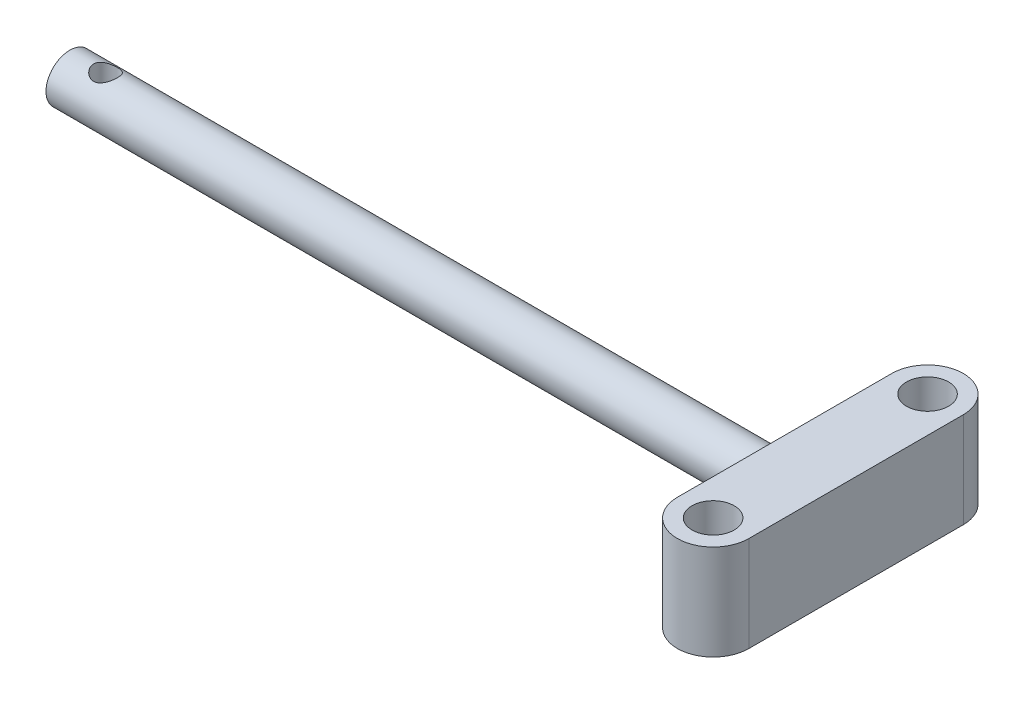
from build123d import *

# Parameters (mm, degrees)
BOSS_EXTRUDE1_DEPTH = 5.08
CUT_EXTRUDE1_REACH  = 12.16
SKETCH4_R           = 2.2479
SKETCH5_R           = 2.54
BOSS_EXTRUDE2_DEPTH = 76.2
CUT_EXTRUDE5_REACH  = 9.62
SKETCH6_R           = 1.27


with BuildPart() as part:
    # Sketch2 → Boss-Extrude1 (new body, symmetric)
    with BuildSketch(Plane(origin=(0, 0, 0), x_dir=(1, 0, 0), z_dir=(0, 1, 0))):
        with BuildLine():
            Line((-50.935337995, 2.421627074), (-50.935337995, -2.138056527))
            Line((-50.935337995, -2.138056527), (-50.935337995, -11.43))
            ThreePointArc((-50.935337995, -11.43), (-47.125337995, -15.24), (-43.315337995, -11.43))
            Line((-43.315337995, -11.43), (-43.315337995, 11.43))
            ThreePointArc((-43.315337995, 11.43), (-47.125337995, 15.24), (-50.935337995, 11.43))
            Line((-50.935337995, 11.43), (-50.935337995, 2.421627074))
        make_face()
    extrude(amount=BOSS_EXTRUDE1_DEPTH, both=True)

    # Sketch4 → Cut-Extrude1 (cut, up to next)
    with BuildSketch(Plane(origin=(0, 5.08, 0), x_dir=(1, 0, 0), z_dir=(0, 1, 0)), mode=Mode.PRIVATE) as cut_extrude1_sk1:
        with Locations((-47.125337995, 11.43)):
            Circle(SKETCH4_R)
    cut_extrude1_tool1 = extrude(cut_extrude1_sk1.sketch, amount=-CUT_EXTRUDE1_REACH, mode=Mode.PRIVATE) & part.part
    add(cut_extrude1_tool1.solids().sort_by_distance((-47.125338, 5.08, -11.43))[0], mode=Mode.SUBTRACT)
    # Sketch4 → Cut-Extrude1 (cut, up to next)
    with BuildSketch(Plane(origin=(0, 5.08, 0), x_dir=(1, 0, 0), z_dir=(0, 1, 0)), mode=Mode.PRIVATE) as cut_extrude1_sk2:
        with Locations((-47.125337995, -11.43)):
            Circle(SKETCH4_R)
    cut_extrude1_tool2 = extrude(cut_extrude1_sk2.sketch, amount=-CUT_EXTRUDE1_REACH, mode=Mode.PRIVATE) & part.part
    add(cut_extrude1_tool2.solids().sort_by_distance((-47.125338, 5.08, 11.43))[0], mode=Mode.SUBTRACT)

    # Sketch5 → Boss-Extrude2 (add)
    with BuildSketch(Plane.ZY.offset(50.935337995)):
        Circle(SKETCH5_R)
    extrude(amount=BOSS_EXTRUDE2_DEPTH)

    # Sketch6 → Cut-Extrude5 (cut, up to next)
    with BuildSketch(Plane(origin=(0, 2.54, 0), x_dir=(1, 0, 0), z_dir=(0, 1, 0)), mode=Mode.PRIVATE) as cut_extrude5_sk1:
        with Locations((-123.325337995, 0)):
            Circle(SKETCH6_R)
    cut_extrude5_tool1 = extrude(cut_extrude5_sk1.sketch, amount=-CUT_EXTRUDE5_REACH, mode=Mode.PRIVATE) & part.part
    add(cut_extrude5_tool1.solids().sort_by_distance((-123.325338, 2.54, 0))[0], mode=Mode.SUBTRACT)


solid = part.part
